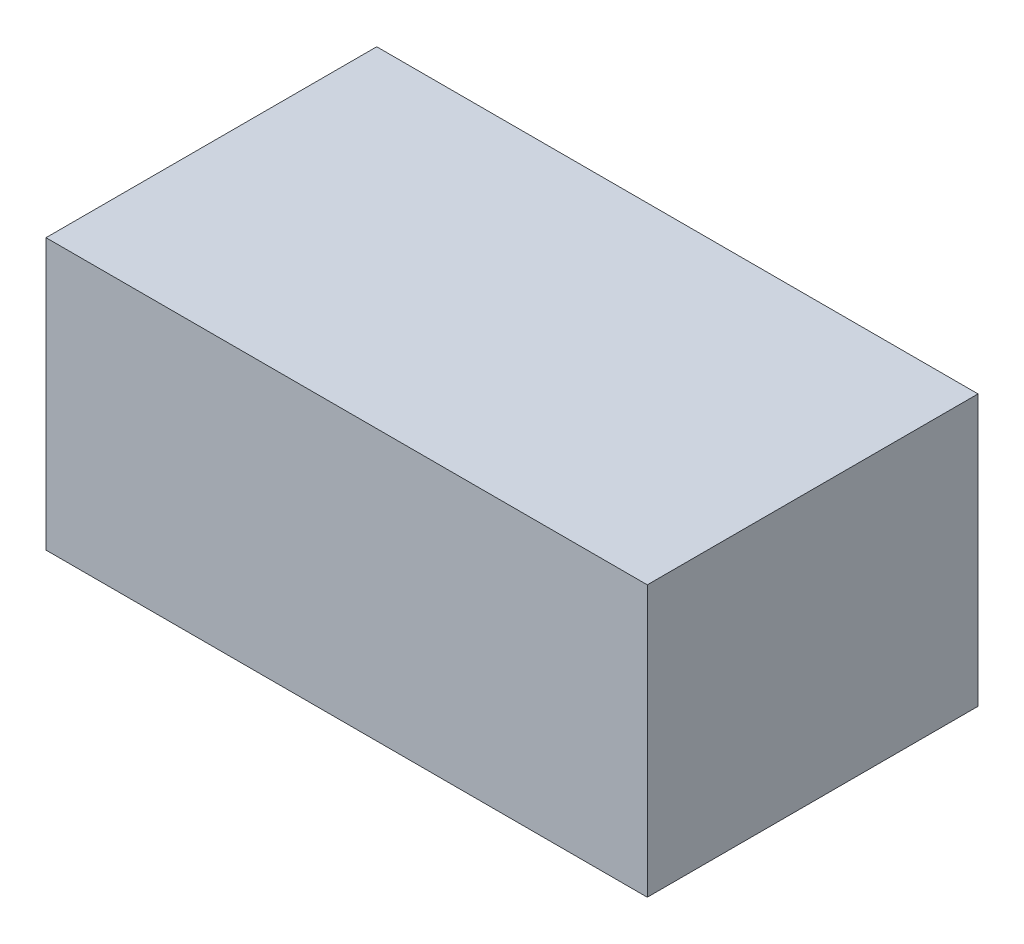
from build123d import *

# Parameters (mm, degrees)
ESQUISSE1_W        = 100
ESQUISSE1_H        = 45
BOSS_EXTRU_1_DEPTH = 55


with BuildPart() as part:
    # Esquisse1 → Boss.-Extru.1 (new body)
    with BuildSketch(Plane.XY):
        with Locations((50, 22.5)):
            Rectangle(ESQUISSE1_W, ESQUISSE1_H)
    extrude(amount=BOSS_EXTRU_1_DEPTH)


solid = part.part
